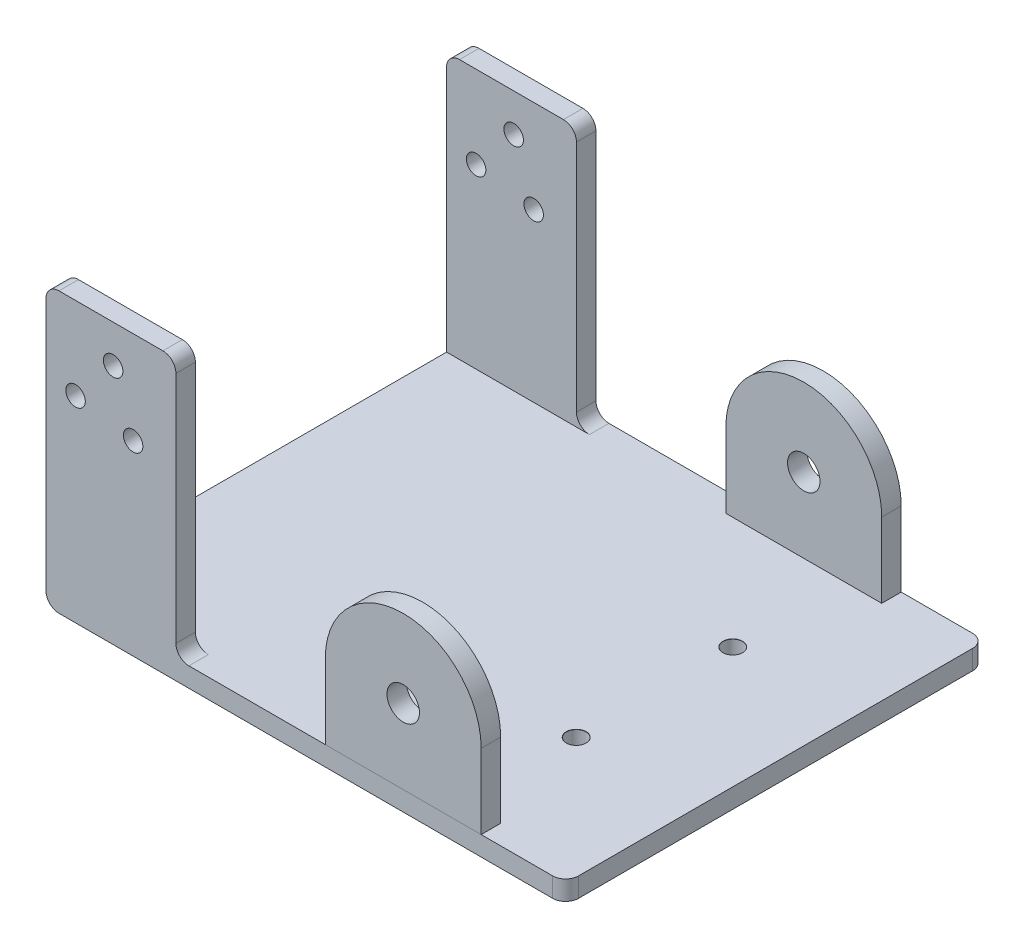
from build123d import *

# Parameters (mm, degrees)
SKETCH1_W                       = 80
SKETCH1_H                       = 64.67
BOSS_EXTRUDE1_DEPTH             = 3
SKETCH2_W                       = 20
SKETCH2_H                       = 3
BOSS_EXTRUDE2_DEPTH             = 40
F_3_0MM_DOWEL_HOLE1_D           = 3
F_3_0MM_DOWEL_HOLE1_CSINK_D     = 3.05
F_3_0MM_DOWEL_HOLE1_CSINK_ANGLE = 90
FILLET1_R                       = 2
F_3_0MM_DOWEL_HOLE2_D           = 3
F_3_0MM_DOWEL_HOLE2_CSINK_D     = 3.05
F_3_0MM_DOWEL_HOLE2_CSINK_ANGLE = 90
SKETCH9_R                       = 2.5
BOSS_EXTRUDE3_DEPTH             = 3
SKETCH10_R                      = 2.5
BOSS_EXTRUDE4_DEPTH             = 3


with BuildPart() as part:
    # Sketch1 → Boss-Extrude1 (new body)
    with BuildSketch(Plane(origin=(0, 0, 0), x_dir=(1, 0, 0), z_dir=(0, 1, 0))):
        Rectangle(SKETCH1_W, SKETCH1_H)
    extrude(amount=BOSS_EXTRUDE1_DEPTH)

    # Sketch2 → Boss-Extrude2 (add)
    with BuildSketch(Plane(origin=(0, 3, 0), x_dir=(1, 0, 0), z_dir=(0, 1, 0))):
        with Locations((-30, 30.835)):
            Rectangle(SKETCH2_W, SKETCH2_H)
        with Locations((-30, -30.835)):
            Rectangle(SKETCH2_W, SKETCH2_H)
    extrude(amount=BOSS_EXTRUDE2_DEPTH)

    # Ø3.0mm Dowel Hole1 (through all)
    with Locations(Plane(origin=(0, 0, -32.335), x_dir=(-1, 0, 0), z_dir=(0, 0, -1))):
        with Locations((26.587155595, 28.720962624), (35.450420321, 30.283824867), (29.665309553, 37.178206159)):
            CounterSinkHole(F_3_0MM_DOWEL_HOLE1_D / 2, F_3_0MM_DOWEL_HOLE1_CSINK_D / 2, counter_sink_angle=F_3_0MM_DOWEL_HOLE1_CSINK_ANGLE)

    # Fillet1
    fillet1_edges = [part.edges().sort_by_distance(p)[0] for p in [
        (-20, 3, -30.835),
        (-40, 43, -30.835),
        (-20, 43, -30.835),
        (-20, 3, 30.835),
        (-40, 43, 30.835),
        (-20, 43, 30.835),
        (-40, 0, 0),
        (40, 1.5, 32.335),
        (40, 1.5, -32.335),
    ]]
    fillet(fillet1_edges, radius=FILLET1_R)

    # Ø3.0mm Dowel Hole2 (through all)
    with Locations(Plane(origin=(0, 3, 0), x_dir=(1, 0, 0), z_dir=(0, 1, 0))):
        with Locations((21.35, 12.05), (21.35, -12.05)):
            CounterSinkHole(F_3_0MM_DOWEL_HOLE2_D / 2, F_3_0MM_DOWEL_HOLE2_CSINK_D / 2, counter_sink_angle=F_3_0MM_DOWEL_HOLE2_CSINK_ANGLE)


with BuildPart() as body_2:
    # Sketch9 → Boss-Extrude3 (new body)
    with BuildSketch(Plane(origin=(0, 0, -32.335), x_dir=(-1, 0, 0), z_dir=(0, 0, -1))):
        with BuildLine():
            Line((-27, 3), (-27, 14.5))
            ThreePointArc((-27, 14.5), (-15, 26.5), (-3, 14.5))
            Line((-3, 14.5), (-3, 3))
            Line((-3, 3), (-27, 3))
        make_face()
        with Locations((-15, 14.5)):
            Circle(SKETCH9_R, mode=Mode.SUBTRACT)
    extrude(amount=-BOSS_EXTRUDE3_DEPTH)


with BuildPart() as body_3:
    # Sketch10 → Boss-Extrude4 (new body)
    with BuildSketch(Plane.XY.offset(32.335)):
        with BuildLine():
            Line((3, 3), (27, 3))
            Line((27, 3), (27, 14.5))
            ThreePointArc((27, 14.5), (15, 26.5), (3, 14.5))
            Line((3, 14.5), (3, 3))
        make_face()
        with Locations((15, 14.5)):
            Circle(SKETCH10_R, mode=Mode.SUBTRACT)
    extrude(amount=-BOSS_EXTRUDE4_DEPTH)


solid = Compound([part.part, body_2.part, body_3.part])
